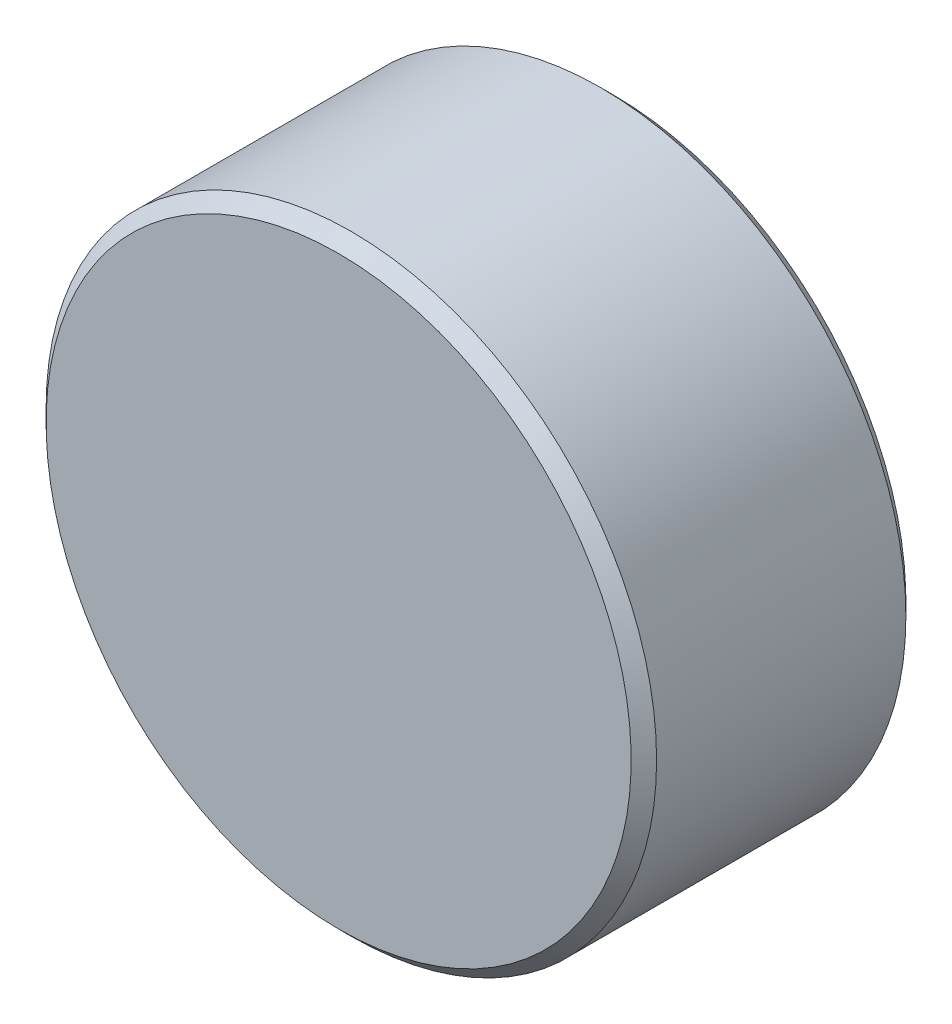
from build123d import *


with BuildPart() as part:
    # Sketch2 → Revolve1 (revolve)
    with BuildSketch(Plane(origin=(0, 0, 0), x_dir=(0, 0, -1), z_dir=(1, 0, 0))):
        Polygon((-14.2875, 0), (-14.2875, 30.427083333), (-12.964583333, 31.75), (12.964583333, 31.75), (14.2875, 30.427083333), (14.2875, 25.732316667), (12.964583333, 24.4094), (0.8001, 24.4094), (0.8001, 0), align=None)
    revolve(axis=Axis((0, 0, -14.2875), (0, 0, 1)))


solid = part.part
